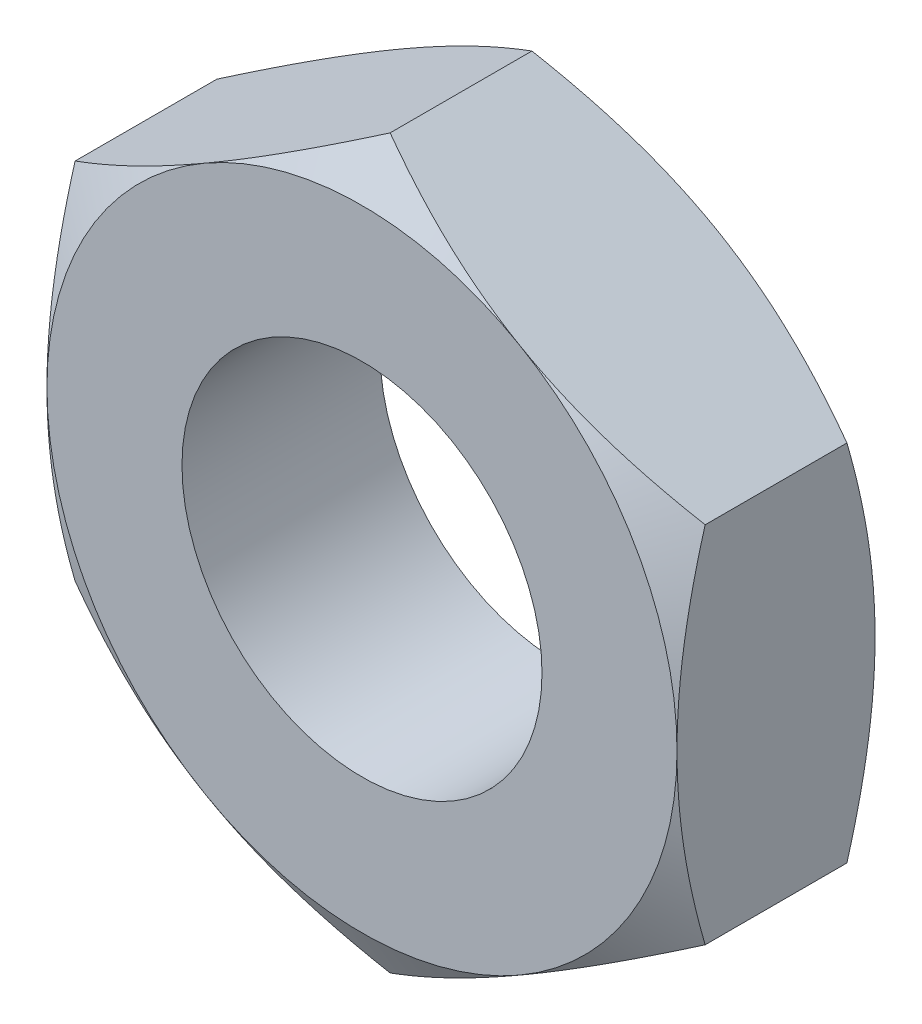
from build123d import *

# Parameters (mm, degrees)
SZKIC1_R                    = 2
DODANIE_WYCI_GNI_CIE1_DEPTH = 2.2


with BuildPart() as part:
    # Szkic1 → Dodanie-wyciągnięcie1 (new body)
    with BuildSketch(Plane.XY):
        Polygon((3.5, 2.020725942), (0, 4.041451884), (-3.5, 2.020725942), (-3.5, -2.020725942), (0, -4.041451884), (3.5, -2.020725942), align=None)
        Circle(SZKIC1_R, mode=Mode.SUBTRACT)
    extrude(amount=DODANIE_WYCI_GNI_CIE1_DEPTH)

    # Szkic2 → Wycięcie-obrót1 (revolve, cut)
    with BuildSketch(Plane(origin=(0, 0, 0), x_dir=(1, 0, 0), z_dir=(0, 1, 0))):
        Polygon((-5.405255888, -2.2), (-3.5, -2.2), (-5.405255888, -1.1), align=None)
        Polygon((-5.405255888, -1.1), (-3.5, 0), (-5.405255888, 0), align=None)
    revolve(axis=Axis((0, 0, 9.891098034), (0, 0, -1)), mode=Mode.SUBTRACT)


solid = part.part
